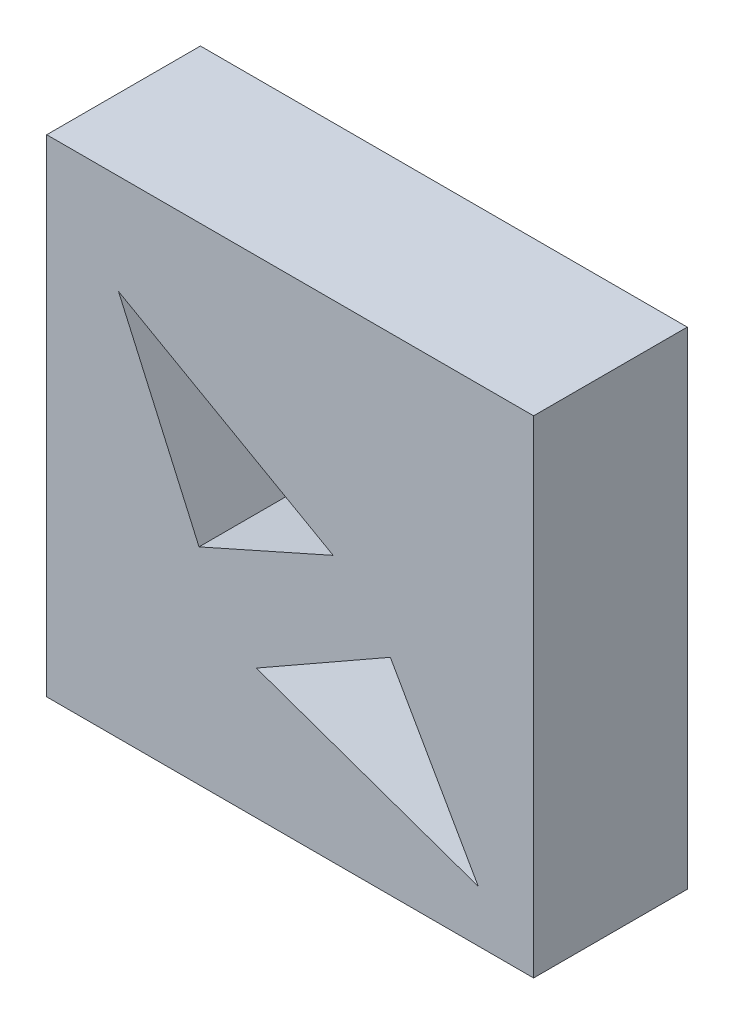
from build123d import *

# Parameters (mm, degrees)
ESQUISSE1_W             = 80
ESQUISSE1_H             = 80
BOSS_EXTRU_1_DEPTH      = 25.25
ENL_V_MAT_EXTRU_1_DEPTH = 25.25


with BuildPart() as part:
    # Esquisse1 → Boss.-Extru.1 (new body)
    with BuildSketch(Plane.XY):
        with Locations((40, 40)):
            Rectangle(ESQUISSE1_W, ESQUISSE1_H)
    extrude(amount=BOSS_EXTRU_1_DEPTH)

    # Esquisse2 → Enlèv. mat.-Extru.1 (cut)
    with BuildSketch(Plane.XY.offset(25.25)):
        Polygon((11.787944312, 63.60583742), (25.026815154, 33.864532302), (47.069224154, 43.676361494), align=None)
        Polygon((34.444148003, 21.326107713), (56.460422486, 33.864532302), (70.917940935, 8.478512531), align=None)
    extrude(amount=-ENL_V_MAT_EXTRU_1_DEPTH, mode=Mode.SUBTRACT)


solid = part.part
